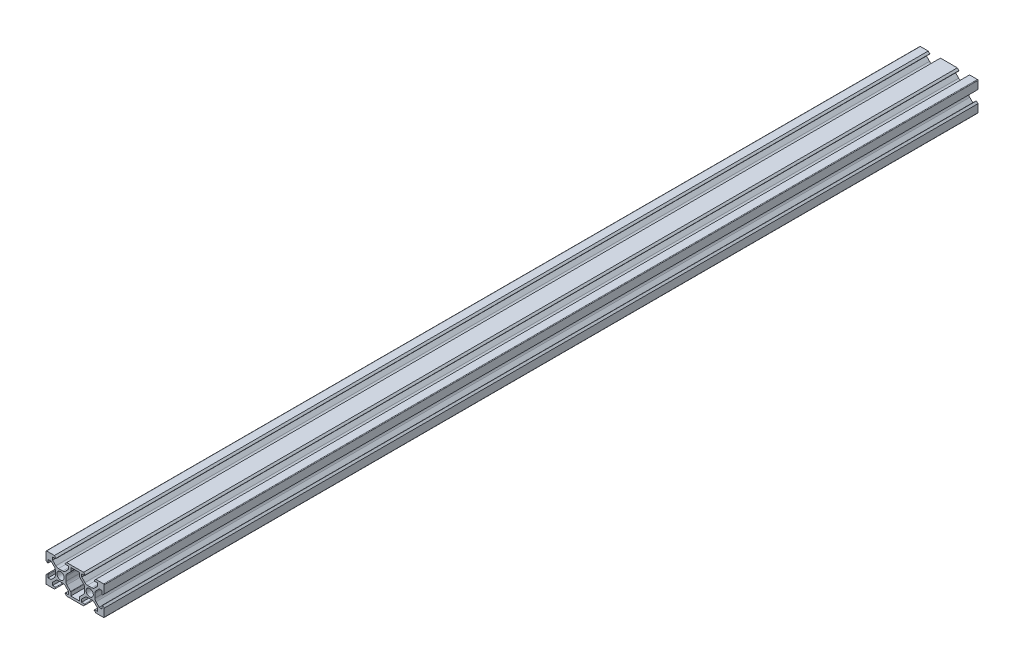
from build123d import *

# Parameters (mm, degrees)
RESSALTO_EXTRUS_O1_DEPTH = 300


with BuildPart() as part:
    # Esboço1 → Ressalto-extrusão1 (new body, symmetric)
    with BuildSketch(Plane.XY):
        with BuildLine():
            Line((-13.1, 8.9), (-14.2, 10))
            Line((-14.2, 10), (-19.6, 10))
            ThreePointArc((-19.6, 10), (-19.882842712, 9.882842712), (-20, 9.6))
            Line((-20, 9.6), (-20, 4.2))
            Line((-20, 4.2), (-18.9, 3.1))
            ThreePointArc((-18.9, 3.1), (-18.617157287, 3.217157287), (-18.5, 3.5))
            Line((-18.5, 3.5), (-18.5, 5.5))
            Line((-18.5, 5.5), (-16.560660172, 5.5))
            Line((-16.560660172, 5.5), (-14.332233047, 3.271572875))
            ThreePointArc((-14.332233047, 3.271572875), (-13.790301169, 2.460514503), (-13.6, 1.503805922))
            Line((-13.6, 1.503805922), (-13.6, 0))
            Line((-13.6, 0), (-13.6, -1.503805922))
            ThreePointArc((-13.6, -1.503805922), (-13.790301169, -2.460514503), (-14.332233047, -3.271572875))
            Line((-14.332233047, -3.271572875), (-16.560660172, -5.5))
            Line((-16.560660172, -5.5), (-18.5, -5.5))
            Line((-18.5, -5.5), (-18.5, -3.5))
            ThreePointArc((-18.5, -3.5), (-18.617157287, -3.217157288), (-18.9, -3.1))
            Line((-18.9, -3.1), (-20, -4.2))
            Line((-20, -4.2), (-20, -9.6))
            ThreePointArc((-20, -9.6), (-19.882842712, -9.882842712), (-19.6, -10))
            Line((-19.6, -10), (-14.2, -10))
            Line((-14.2, -10), (-13.1, -8.9))
            ThreePointArc((-13.1, -8.9), (-13.217157287, -8.617157288), (-13.5, -8.5))
            Line((-13.5, -8.5), (-15.5, -8.5))
            Line((-15.5, -8.5), (-15.5, -6.560660172))
            Line((-15.5, -6.560660172), (-13.271572875, -4.332233047))
            ThreePointArc((-13.271572875, -4.332233047), (-12.460514503, -3.790301169), (-11.503805922, -3.6))
            Line((-11.503805922, -3.6), (-10, -3.6))
            Line((-10, -3.6), (-8.496194078, -3.6))
            ThreePointArc((-8.496194078, -3.6), (-7.539485497, -3.790301169), (-6.728427125, -4.332233047))
            Line((-6.728427125, -4.332233047), (-4.5, -6.560660172))
            Line((-4.5, -6.560660172), (-4.5, -8.5))
            Line((-4.5, -8.5), (-6.5, -8.5))
            ThreePointArc((-6.5, -8.5), (-6.782842712, -8.617157288), (-6.9, -8.9))
            Line((-6.9, -8.9), (-5.8, -10))
            Line((-5.8, -10), (5.8, -10))
            Line((5.8, -10), (6.9, -8.9))
            ThreePointArc((6.9, -8.9), (6.782842712, -8.617157288), (6.5, -8.5))
            Line((6.5, -8.5), (4.5, -8.5))
            Line((4.5, -8.5), (4.5, -6.560660172))
            Line((4.5, -6.560660172), (6.728427125, -4.332233047))
            ThreePointArc((6.728427125, -4.332233047), (7.539485497, -3.790301169), (8.496194078, -3.6))
            Line((8.496194078, -3.6), (10, -3.6))
            Line((10, -3.6), (11.503805922, -3.6))
            ThreePointArc((11.503805922, -3.6), (12.460514503, -3.790301169), (13.271572875, -4.332233047))
            Line((13.271572875, -4.332233047), (15.5, -6.560660172))
            Line((15.5, -6.560660172), (15.5, -8.5))
            Line((15.5, -8.5), (13.5, -8.5))
            ThreePointArc((13.5, -8.5), (13.217157287, -8.617157288), (13.1, -8.9))
            Line((13.1, -8.9), (14.2, -10))
            Line((14.2, -10), (19.6, -10))
            ThreePointArc((19.6, -10), (19.882842712, -9.882842712), (20, -9.6))
            Line((20, -9.6), (20, -4.2))
            Line((20, -4.2), (18.9, -3.1))
            ThreePointArc((18.9, -3.1), (18.617157287, -3.217157288), (18.5, -3.5))
            Line((18.5, -3.5), (18.5, -5.5))
            Line((18.5, -5.5), (16.560660172, -5.5))
            Line((16.560660172, -5.5), (14.332233047, -3.271572875))
            ThreePointArc((14.332233047, -3.271572875), (13.790301169, -2.460514503), (13.6, -1.503805922))
            Line((13.6, -1.503805922), (13.6, 0))
            Line((13.6, 0), (13.6, 1.503805922))
            ThreePointArc((13.6, 1.503805922), (13.790301169, 2.460514503), (14.332233047, 3.271572875))
            Line((14.332233047, 3.271572875), (16.560660172, 5.5))
            Line((16.560660172, 5.5), (18.5, 5.5))
            Line((18.5, 5.5), (18.5, 3.5))
            ThreePointArc((18.5, 3.5), (18.617157287, 3.217157287), (18.9, 3.1))
            Line((18.9, 3.1), (20, 4.2))
            Line((20, 4.2), (20, 9.6))
            ThreePointArc((20, 9.6), (19.882842712, 9.882842712), (19.6, 10))
            Line((19.6, 10), (14.2, 10))
            Line((14.2, 10), (13.1, 8.9))
            ThreePointArc((13.1, 8.9), (13.217157287, 8.617157287), (13.5, 8.5))
            Line((13.5, 8.5), (15.5, 8.5))
            Line((15.5, 8.5), (15.5, 6.560660172))
            Line((15.5, 6.560660172), (13.271572875, 4.332233047))
            ThreePointArc((13.271572875, 4.332233047), (12.460514503, 3.790301169), (11.503805922, 3.6))
            Line((11.503805922, 3.6), (10, 3.6))
            Line((10, 3.6), (8.496194078, 3.6))
            ThreePointArc((8.496194078, 3.6), (7.539485497, 3.790301169), (6.728427125, 4.332233047))
            Line((6.728427125, 4.332233047), (4.5, 6.560660172))
            Line((4.5, 6.560660172), (4.5, 8.5))
            Line((4.5, 8.5), (6.5, 8.5))
            ThreePointArc((6.5, 8.5), (6.782842712, 8.617157288), (6.9, 8.9))
            Line((6.9, 8.9), (5.8, 10))
            Line((5.8, 10), (-5.8, 10))
            Line((-5.8, 10), (-6.9, 8.9))
            ThreePointArc((-6.9, 8.9), (-6.782842712, 8.617157288), (-6.5, 8.5))
            Line((-6.5, 8.5), (-4.5, 8.5))
            Line((-4.5, 8.5), (-4.5, 6.560660172))
            Line((-4.5, 6.560660172), (-6.728427125, 4.332233047))
            ThreePointArc((-6.728427125, 4.332233047), (-7.539485497, 3.790301169), (-8.496194078, 3.6))
            Line((-8.496194078, 3.6), (-10, 3.6))
            Line((-10, 3.6), (-11.503805922, 3.6))
            ThreePointArc((-11.503805922, 3.6), (-12.460514503, 3.790301169), (-13.271572875, 4.332233047))
            Line((-13.271572875, 4.332233047), (-15.5, 6.560660172))
            Line((-15.5, 6.560660172), (-15.5, 8.5))
            Line((-15.5, 8.5), (-13.5, 8.5))
            ThreePointArc((-13.5, 8.5), (-13.217157287, 8.617157287), (-13.1, 8.9))
        make_face()
        with BuildLine():
            Line((-3, 8.5), (3, 8.5))
            Line((3, 8.5), (3, 6.105025253))
            ThreePointArc((3, 6.105025253), (3.030448187, 5.95195188), (3.117157288, 5.822182541))
            Line((3.117157288, 5.822182541), (5.667766953, 3.271572875))
            ThreePointArc((5.667766953, 3.271572875), (6.209698831, 2.460514503), (6.4, 1.503805922))
            Line((6.4, 1.503805922), (6.4, 0))
            Line((6.4, 0), (6.4, -1.503805922))
            ThreePointArc((6.4, -1.503805922), (6.209698831, -2.460514503), (5.667766953, -3.271572875))
            Line((5.667766953, -3.271572875), (3.117157288, -5.822182541))
            ThreePointArc((3.117157288, -5.822182541), (3.030448187, -5.95195188), (3, -6.105025253))
            Line((3, -6.105025253), (3, -8.5))
            Line((3, -8.5), (-3, -8.5))
            Line((-3, -8.5), (-3, -6.105025253))
            ThreePointArc((-3, -6.105025253), (-3.030448187, -5.95195188), (-3.117157288, -5.822182541))
            Line((-3.117157288, -5.822182541), (-5.667766953, -3.271572875))
            ThreePointArc((-5.667766953, -3.271572875), (-6.209698831, -2.460514503), (-6.4, -1.503805922))
            Line((-6.4, -1.503805922), (-6.4, 0))
            Line((-6.4, 0), (-6.4, 1.503805922))
            ThreePointArc((-6.4, 1.503805922), (-6.209698831, 2.460514503), (-5.667766953, 3.271572875))
            Line((-5.667766953, 3.271572875), (-3.117157288, 5.822182541))
            ThreePointArc((-3.117157288, 5.822182541), (-3.030448187, 5.95195188), (-3, 6.105025253))
            Line((-3, 6.105025253), (-3, 8.5))
        make_face(mode=Mode.SUBTRACT)
        with BuildLine():
            ThreePointArc((-10, 2.5), (-11.767766953, 1.767766953), (-12.5, 0))
            ThreePointArc((-12.5, 0), (-11.767766953, -1.767766953), (-10, -2.5))
            ThreePointArc((-10, -2.5), (-8.232233047, -1.767766953), (-7.5, 0))
            ThreePointArc((-7.5, 0), (-8.232233047, 1.767766953), (-10, 2.5))
        make_face(mode=Mode.SUBTRACT)
        with BuildLine():
            ThreePointArc((12.5, 0), (11.767766953, -1.767766953), (10, -2.5))
            ThreePointArc((10, -2.5), (8.232233047, -1.767766953), (7.5, 0))
            ThreePointArc((7.5, 0), (8.232233047, 1.767766953), (10, 2.5))
            ThreePointArc((10, 2.5), (11.767766953, 1.767766953), (12.5, 0))
        make_face(mode=Mode.SUBTRACT)
    extrude(amount=RESSALTO_EXTRUS_O1_DEPTH, both=True)


solid = part.part
